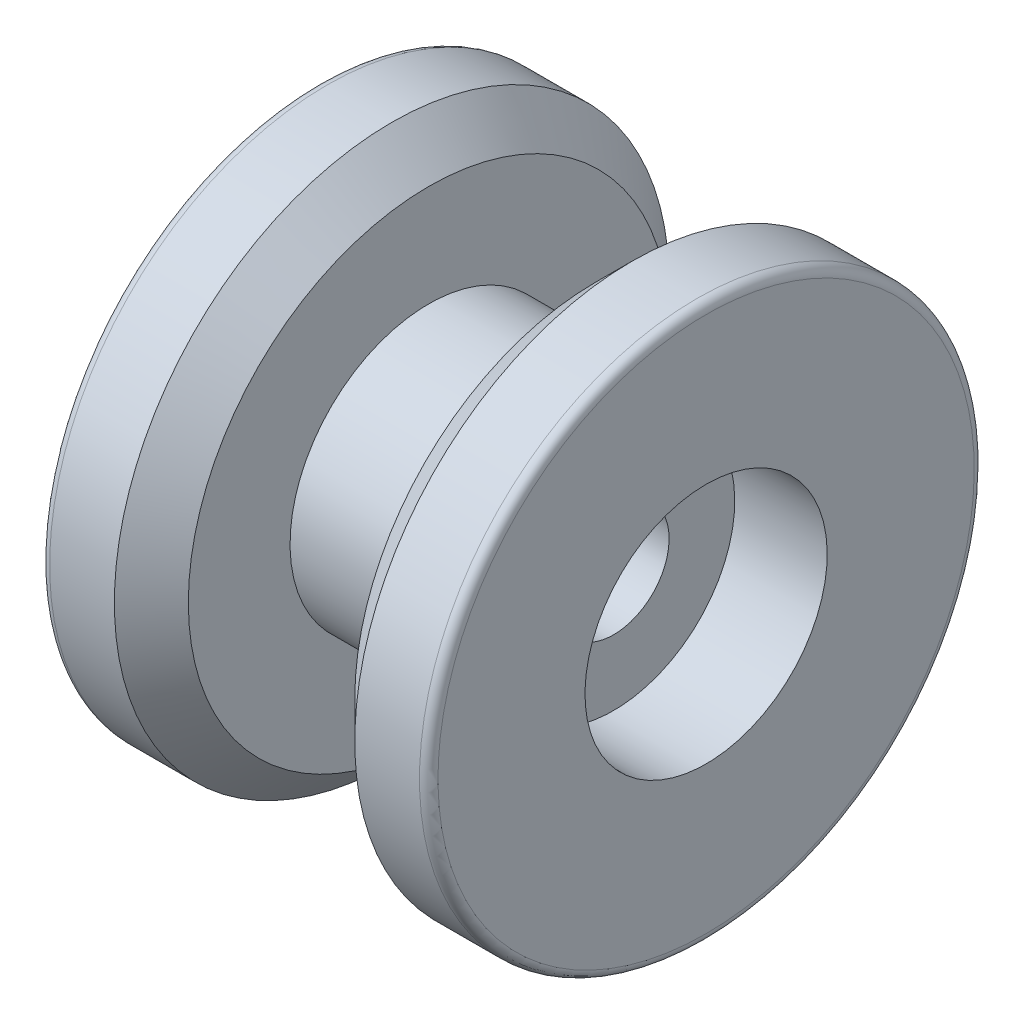
from build123d import *

# Parameters (mm, degrees)
SKETCH2_R               = 9
BOSS_EXTRUDE1_DEPTH     = 10
SKETCH3_R               = 6
CUT_EXTRUDE1_DEPTH      = 53
CHAMFER1_SIZE           = 4
FILLET4_R               = 1
SKETCH8_W               = 10
SKETCH8_H               = 21.176663605
CUT_EXTRUDE3_DEPTH      = 31
CUT_EXTRUDE3_DEPTH_BACK = 31
SKETCH10_R              = 13.1
CUT_EXTRUDE4_DEPTH      = 10


with BuildPart() as part:
    # Sketch1 → Revolve1 (revolve)
    with BuildSketch(Plane.XY):
        Polygon((-21, 0), (21, 0), (21, 30), (9, 30), (9, 15), (-9, 15), (-9, 30), (-21, 30), align=None)
    revolve(axis=Axis((-21, 0, 0), (1, 0, 0)))

    # Sketch2 → Boss-Extrude1 (add)
    with BuildSketch(Plane(origin=(21, 0, 0), x_dir=(0, 0, -1), z_dir=(1, 0, 0))):
        Circle(SKETCH2_R)
    extrude(amount=BOSS_EXTRUDE1_DEPTH)

    # Sketch3 → Cut-Extrude1 (cut, through all)
    with BuildSketch(Plane(origin=(31, 0, 0), x_dir=(0, 0, -1), z_dir=(1, 0, 0))):
        Circle(SKETCH3_R)
    extrude(amount=-CUT_EXTRUDE1_DEPTH, mode=Mode.SUBTRACT)

    # Chamfer1
    chamfer1_edges = [part.edges().sort_by_distance(p)[0] for p in [
        (-9, -30, 0),
        (9, -30, 0),
    ]]
    chamfer(chamfer1_edges, length=CHAMFER1_SIZE)

    # Fillet4
    fillet4_edges = [part.edges().sort_by_distance(p)[0] for p in [
        (-21, -30, 0),
        (21, -30, 0),
    ]]
    fillet(fillet4_edges, radius=FILLET4_R)

    # Sketch8 → Cut-Extrude3 (cut, two sides)
    with BuildSketch(Plane(origin=(0, 0, 0), x_dir=(1, 0, 0), z_dir=(0, 1, 0))) as cut_extrude3_sk:
        with Locations((26, 0.476968454)):
            Rectangle(SKETCH8_W, SKETCH8_H)
    extrude(amount=CUT_EXTRUDE3_DEPTH, mode=Mode.SUBTRACT)
    extrude(cut_extrude3_sk.sketch, amount=-CUT_EXTRUDE3_DEPTH_BACK, mode=Mode.SUBTRACT)

    # Sketch10 → Cut-Extrude4 (cut)
    with BuildSketch(Plane(origin=(21, 0, 0), x_dir=(0, 0, -1), z_dir=(1, 0, 0))):
        Circle(SKETCH10_R)
    extrude(amount=-CUT_EXTRUDE4_DEPTH, mode=Mode.SUBTRACT)


solid = part.part
